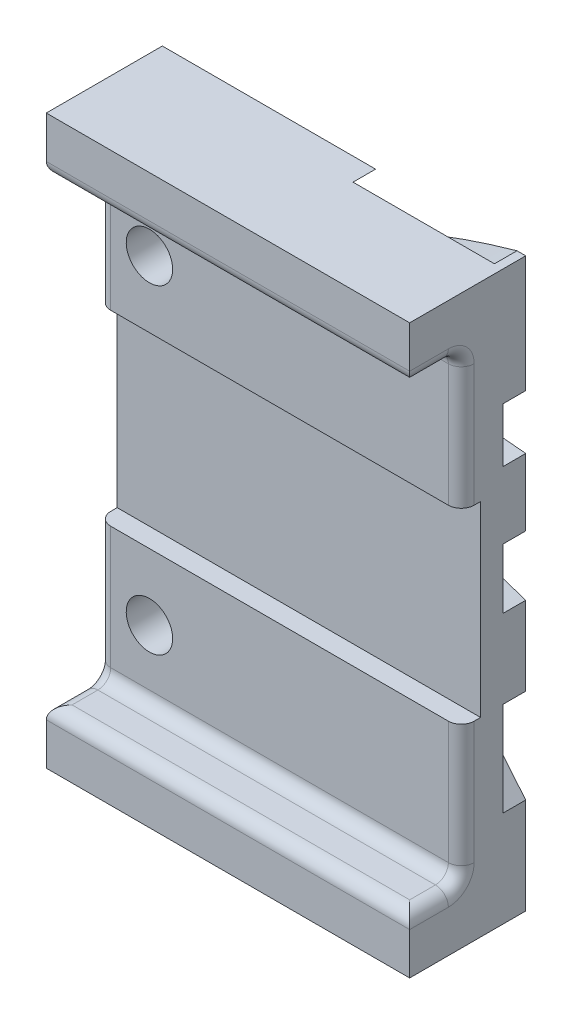
from build123d import *

# Parameters (mm, degrees)
SKETCH1_W                = 28.18
SKETCH1_H                = 44
BOSS_EXTRUDE1_DEPTH      = 11
BOSS_EXTRUDE1_DEPTH_BACK = 2
CUT_EXTRUDE1_DEPTH       = 37
SKETCH4_W                = 20.18
SKETCH4_H                = 4
CUT_EXTRUDE2_DEPTH       = 48
CUT_EXTRUDE3_DEPTH       = 1.75
SKETCH7_R                = 1.8
CUT_EXTRUDE4_DEPTH       = 23
SKETCH10_W               = 11.795844225
SKETCH10_H               = 4.586005201
CUT_EXTRUDE7_DEPTH       = 53
FILLET1_R                = 1
SKETCH8_R                = 3.25
CUT_EXTRUDE5_DEPTH       = 1.75


with BuildPart() as part:
    # Sketch1 → Boss-Extrude1 (new body, two sides)
    with BuildSketch(Plane.XY) as boss_extrude1_sk:
        Rectangle(SKETCH1_W, SKETCH1_H)
    extrude(amount=BOSS_EXTRUDE1_DEPTH)
    extrude(boss_extrude1_sk.sketch, amount=-BOSS_EXTRUDE1_DEPTH_BACK)

    # Sketch3 → Cut-Extrude1 (cut)
    with BuildSketch(Plane.ZY.offset(14.09)):
        Polygon((8, 7.25), (11, 7.25), (11, -7.25), (8, -7.25), (8, -17.75), (3, -17.75), (3, -7.25), (1.5033938, -7.25), (1.5033938, 7.25), (3, 7.25), (3, 17.75), (8, 17.75), align=None)
    extrude(amount=-CUT_EXTRUDE1_DEPTH, mode=Mode.SUBTRACT)

    # Sketch4 → Cut-Extrude2 (cut)
    with BuildSketch(Plane.XZ.offset(22)):
        with Locations((4, 9)):
            Rectangle(SKETCH4_W, SKETCH4_H)
    extrude(amount=-CUT_EXTRUDE2_DEPTH, mode=Mode.SUBTRACT)

    # Sketch5 → Cut-Extrude3 (cut)
    with BuildSketch(Plane(origin=(0, 0, -2), x_dir=(-1, 0, 0), z_dir=(0, 0, -1))):
        with BuildLine():
            Line((-9.422350513, -22), (-5.513274624, -22))
            add(Edge.make_bspline(
                [(-14.09, 12.943541527), (17.027152303, 14.230895657), (-0.913223026, -5.637747584), (-5.513274624, -22)],
                knots=[0, 0, 0, 0, 0.88215351, 0.88215351, 0.88215351, 0.88215351], degree=3))
            Line((-14.09, 12.943541527), (-14.09, 8.727219843))
            add(Edge.make_bspline(
                [(-14.09, 8.727219843), (12.710361443, 11.678555955), (-5.250487577, -7.026945605), (-9.422350513, -22)],
                knots=[0, 0, 0, 0, 0.871233208, 0.871233208, 0.871233208, 0.871233208], degree=3))
        make_face()
        with BuildLine():
            add(Edge.make_bspline(
                [(-14.09, 3.523280295), (7.913446573, 11.6376574), (-14.09, -14.545652593)],
                knots=[0, 0, 0, 1, 1, 1], degree=2))
            Line((-14.09, 3.523280295), (-14.09, -1.131328535))
            add(Edge.make_bspline(
                [(-14.09, -1.131328535), (-1.654052468, 3.211926994), (-14.09, -7.240502624)],
                knots=[0, 0, 0, 1, 1, 1], degree=2))
            Line((-14.09, -7.240502624), (-14.09, -14.545652593))
        make_face()
        with BuildLine():
            add(Edge.make_bspline(
                [(-2.448223174, 22), (19.56705897, 11.536361781), (5.151599528, -7.62224079), (5.592236917, -22)],
                knots=[0, 0, 0, 0, 0.832841206, 0.832841206, 0.832841206, 0.832841206], degree=3))
            Line((-2.448223174, 22), (-13.413117725, 22))
            add(Edge.make_bspline(
                [(-13.413117725, 22), (18.496116363, 13.047461166), (3.546154763, -4.863207343), (0.001206333, -22)],
                knots=[0, 0, 0, 0, 0.886771983, 0.886771983, 0.886771983, 0.886771983], degree=3))
            Line((0.001206333, -22), (5.592236917, -22))
        make_face()
    extrude(amount=-CUT_EXTRUDE3_DEPTH, mode=Mode.SUBTRACT)

    # Sketch7 → Cut-Extrude4 (cut)
    with BuildSketch(Plane.XY.offset(11)):
        with Locations((-10.09, 12.4)):
            Circle(SKETCH7_R)
        with Locations((-10.09, -12.4)):
            Circle(SKETCH7_R)
    extrude(amount=-CUT_EXTRUDE4_DEPTH, mode=Mode.SUBTRACT)

    # Sketch10 → Cut-Extrude7 (cut)
    with BuildSketch(Plane(origin=(0, 22, 0), x_dir=(1, 0, 0), z_dir=(0, 1, 0))):
        with Locations((-10.712086776, -9.2930026)):
            Rectangle(SKETCH10_W, SKETCH10_H)
    extrude(amount=-CUT_EXTRUDE7_DEPTH, mode=Mode.SUBTRACT)

    # Fillet1
    fillet1_edges = [part.edges().sort_by_distance(p)[0] for p in [
        (-14.09, 17.75, 5),
        (14.09, -12.5, 3),
        (14.09, 12.5, 3),
        (14.09, 17.75, 5),
        (0, -17.75, 3),
        (0, 17.75, 3),
        (-14.09, -12.5, 3),
        (-14.09, -17.75, 5),
        (-14.09, 12.5, 3),
        (14.09, -17.75, 5),
        (0, -17.75, 7),
        (0, 17.75, 7),
    ]]
    fillet(fillet1_edges, radius=FILLET1_R)

    # Sketch8 → Cut-Extrude5 (cut)
    with BuildSketch(Plane(origin=(0, 0, -2), x_dir=(-1, 0, 0), z_dir=(0, 0, -1))):
        with Locations((10.09, -12.4)):
            Circle(SKETCH8_R)
        with Locations((10.09, 12.4)):
            Circle(SKETCH8_R)
    extrude(amount=-CUT_EXTRUDE5_DEPTH, mode=Mode.SUBTRACT)


solid = part.part
